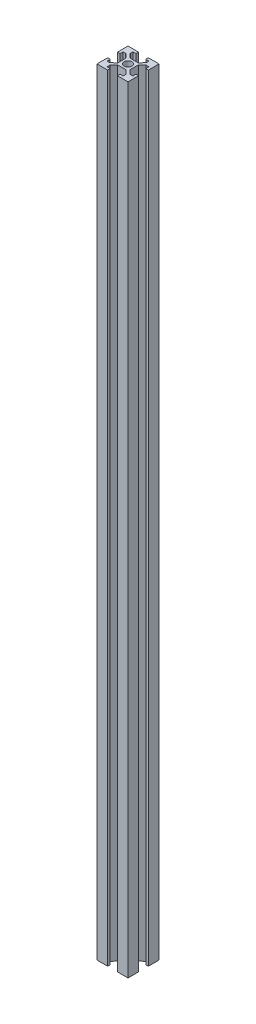
from build123d import *

# Parameters (mm, degrees)
SKETCH_1_W          = 20
SKETCH_1_H          = 20
EXTRUDE_1_DEPTH     = 500
SKETCH_2_R          = 2.5
CUT_EXTRUDE_1_DEPTH = 501


with BuildPart() as part:
    # 草图1 → 凸台-拉伸1 (new body)
    with BuildSketch(Plane(origin=(0, 0, 0), x_dir=(1, 0, 0), z_dir=(0, 1, 0))):
        Rectangle(SKETCH_1_W, SKETCH_1_H)
    extrude(amount=EXTRUDE_1_DEPTH)

    # 草图2 → 切除-拉伸1 (cut, through all)
    with BuildSketch(Plane(origin=(0, 500, 0), x_dir=(1, 0, 0), z_dir=(0, 1, 0))):
        Circle(SKETCH_2_R)
        Polygon((-3.15, 10), (-3.15, 8.3), (-5.15, 8.3), (-5.15, 6.6), (-2.75, 3.9), (2.75, 3.9), (5.15, 6.6), (5.15, 8.3), (3.15, 8.3), (3.15, 10), align=None)
        Polygon((3.9, 2.75), (3.9, -2.75), (6.6, -5.15), (8.3, -5.15), (8.3, -3.15), (10, -3.15), (10, 3.15), (8.3, 3.15), (8.3, 5.15), (6.6, 5.15), align=None)
        Polygon((2.75, -3.9), (-2.75, -3.9), (-5.15, -6.6), (-5.15, -8.3), (-3.15, -8.3), (-3.15, -10), (3.15, -10), (3.15, -8.3), (5.15, -8.3), (5.15, -6.6), align=None)
        Polygon((-3.9, -2.75), (-3.9, 2.75), (-6.6, 5.15), (-8.3, 5.15), (-8.3, 3.15), (-10, 3.15), (-10, -3.15), (-8.3, -3.15), (-8.3, -5.15), (-6.6, -5.15), align=None)
    extrude(amount=-CUT_EXTRUDE_1_DEPTH, mode=Mode.SUBTRACT)


solid = part.part
